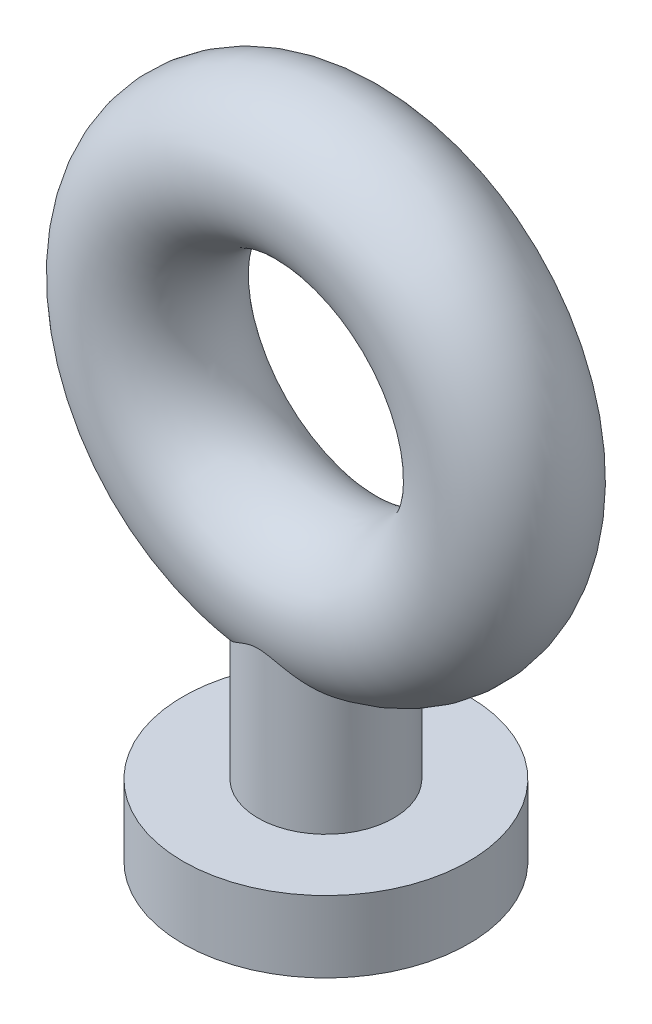
from build123d import *

# Parameters (mm, degrees)
SKETCH_1_R = 1


with BuildPart() as part:
    # 草图1 → 旋转1 (revolve)
    with BuildSketch(Plane(origin=(0, 0, 0), x_dir=(1, 0, 0), z_dir=(0, 1, 0))):
        with Locations((2.5, 0)):
            Circle(SKETCH_1_R)
    revolve(axis=Axis((0, 0, 0), (0, 0, 1)))

    # 草图2 → 旋转2 (revolve)
    with BuildSketch(Plane.XY):
        Polygon((0, -5.868605053), (0, -2.568605053), (0.95, -2.568605053), (0.95, -4.868605053), (2, -4.868605053), (2, -5.868605053), align=None)
    revolve(axis=Axis((0, 0, 0), (0, -1, 0)))


solid = part.part
